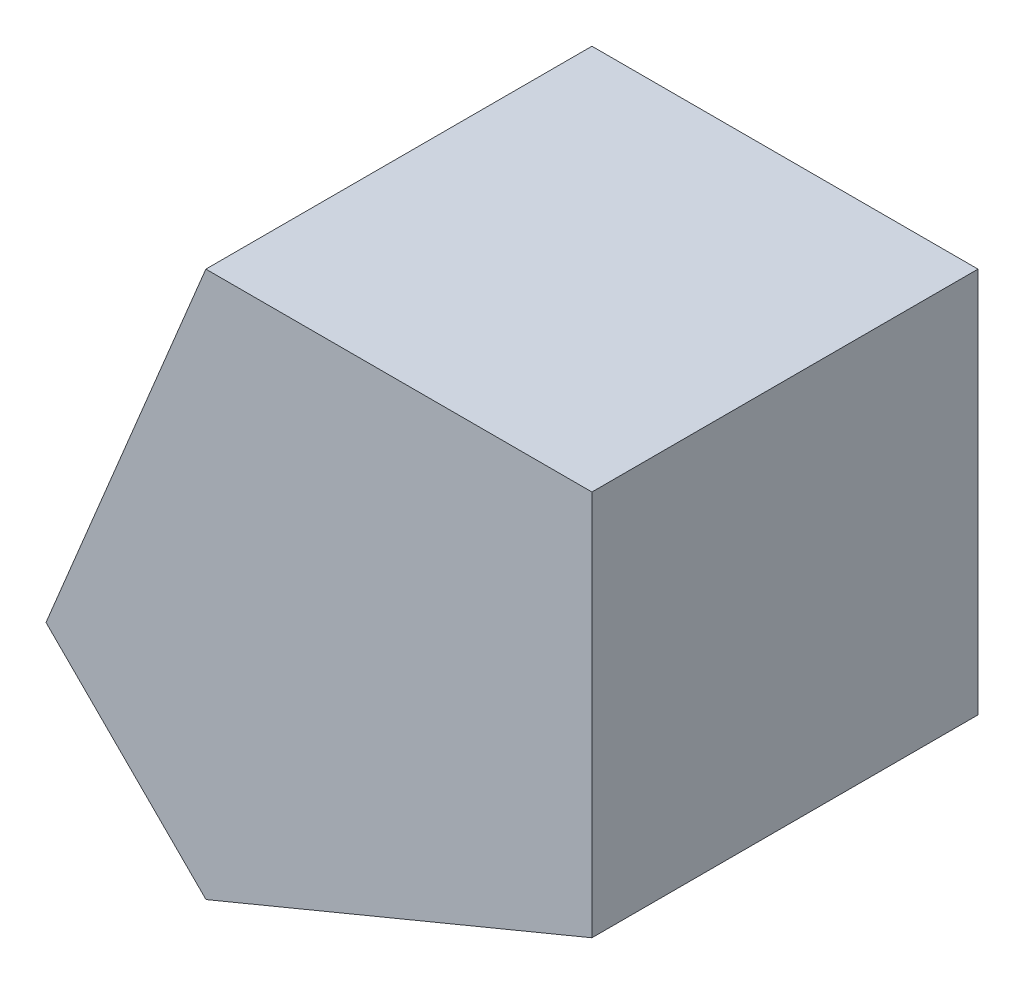
from build123d import *

# Parameters (mm, degrees)
EXTRUDE_1_DEPTH = 10


with BuildPart() as part:
    # 草图1 → 凸台-拉伸1 (new body)
    with BuildSketch(Plane.XY):
        Polygon((16.624762525, 6.247123494), (16.624762525, 16.247123494), (6.624762525, 16.247123494), (2.484127787, 6.250746952), (6.628385983, 2.106488756), align=None)
    extrude(amount=EXTRUDE_1_DEPTH)


solid = part.part
